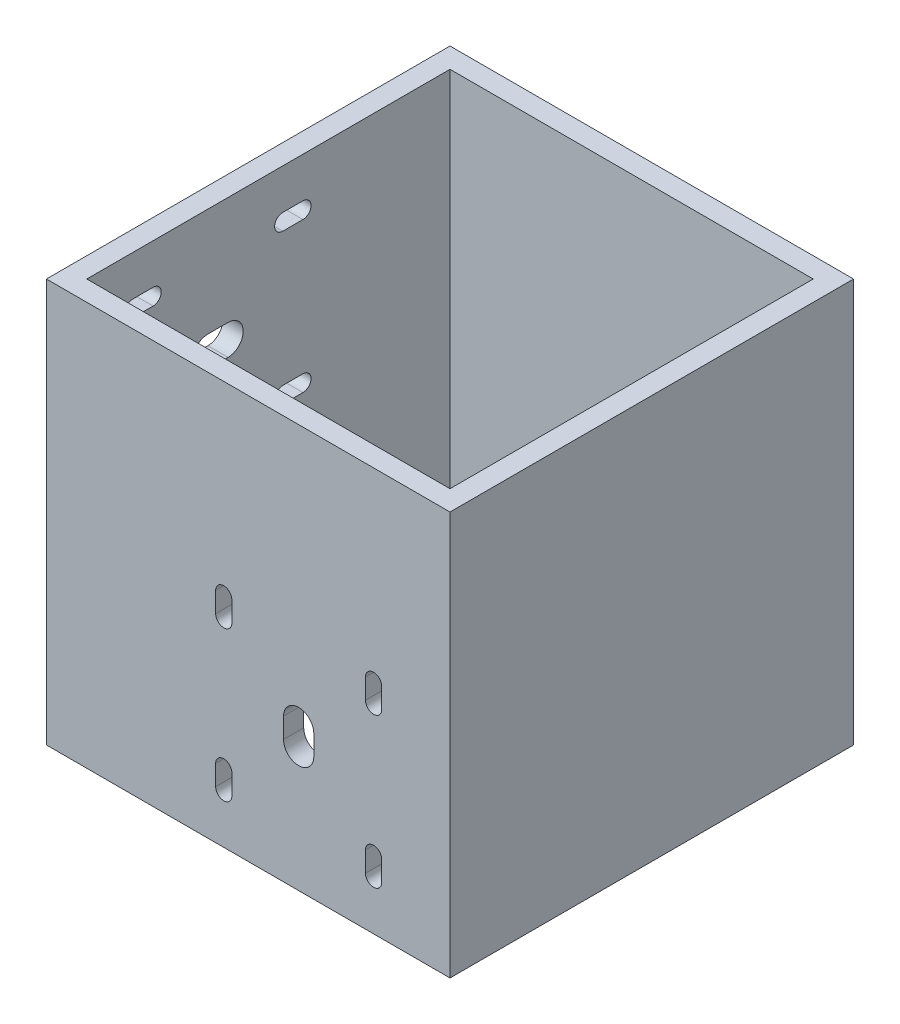
from build123d import *

# Parameters (mm, degrees)
SKETCH2_W           = 127
SKETCH2_H           = 127
SKETCH2_W_2         = 114.3
SKETCH2_H_2         = 114.3
BOSS_EXTRUDE2_DEPTH = 127
CUT_EXTRUDE1_REACH  = 129
CUT_EXTRUDE2_REACH  = 129


with BuildPart() as part:
    # Sketch2 → Boss-Extrude2 (new body)
    with BuildSketch(Plane(origin=(0, 0, 0), x_dir=(1, 0, 0), z_dir=(0, 1, 0))):
        Rectangle(SKETCH2_W, SKETCH2_H)
        Rectangle(SKETCH2_W_2, SKETCH2_H_2, mode=Mode.SUBTRACT)
    extrude(amount=BOSS_EXTRUDE2_DEPTH)

    # Sketch6 → Cut-Extrude1 (cut, up to next)
    with BuildSketch(Plane.ZY.offset(63.5), mode=Mode.PRIVATE) as cut_extrude1_sk1:
        with BuildLine():
            Line((-4.523172318, 109.1946), (-10.873172318, 109.1946))
            ThreePointArc((-10.873172318, 109.1946), (-13.425872318, 111.7473), (-10.873172318, 114.3))
            Line((-10.873172318, 114.3), (-4.523172318, 114.3))
            ThreePointArc((-4.523172318, 114.3), (-1.970472318, 111.7473), (-4.523172318, 109.1946))
        make_face()
    cut_extrude1_tool1 = extrude(cut_extrude1_sk1.sketch, amount=-CUT_EXTRUDE1_REACH, mode=Mode.PRIVATE) & part.part
    add(cut_extrude1_tool1.solids().sort_by_distance((-63.5, 111.7473, -7.698172))[0], mode=Mode.SUBTRACT)
    # Sketch6 → Cut-Extrude1 (cut, up to next)
    with BuildSketch(Plane.ZY.offset(63.5), mode=Mode.PRIVATE) as cut_extrude1_sk2:
        with BuildLine():
            Line((36.273172318, 114.3), (42.623172318, 114.3))
            ThreePointArc((42.623172318, 114.3), (45.175872318, 111.7473), (42.623172318, 109.1946))
            Line((42.623172318, 109.1946), (36.273172318, 109.1946))
            ThreePointArc((36.273172318, 109.1946), (33.720472318, 111.7473), (36.273172318, 114.3))
        make_face()
    cut_extrude1_tool2 = extrude(cut_extrude1_sk2.sketch, amount=-CUT_EXTRUDE1_REACH, mode=Mode.PRIVATE) & part.part
    add(cut_extrude1_tool2.solids().sort_by_distance((-63.5, 111.7473, 39.448172))[0], mode=Mode.SUBTRACT)
    # Sketch6 → Cut-Extrude1 (cut, up to next)
    with BuildSketch(Plane.ZY.offset(63.5), mode=Mode.PRIVATE) as cut_extrude1_sk3:
        with BuildLine():
            Line((36.273172318, 67.153655364), (42.623172318, 67.153655364))
            ThreePointArc((42.623172318, 67.153655364), (45.175872318, 64.600955364), (42.623172318, 62.048255364))
            Line((42.623172318, 62.048255364), (36.273172318, 62.048255364))
            ThreePointArc((36.273172318, 62.048255364), (33.720472318, 64.600955364), (36.273172318, 67.153655364))
        make_face()
    cut_extrude1_tool3 = extrude(cut_extrude1_sk3.sketch, amount=-CUT_EXTRUDE1_REACH, mode=Mode.PRIVATE) & part.part
    add(cut_extrude1_tool3.solids().sort_by_distance((-63.5, 64.600955, 39.448172))[0], mode=Mode.SUBTRACT)
    # Sketch6 → Cut-Extrude1 (cut, up to next)
    with BuildSketch(Plane.ZY.offset(63.5), mode=Mode.PRIVATE) as cut_extrude1_sk4:
        with BuildLine():
            Line((-4.523172318, 62.048255364), (-10.873172318, 62.048255364))
            ThreePointArc((-10.873172318, 62.048255364), (-13.425872318, 64.600955364), (-10.873172318, 67.153655364))
            Line((-10.873172318, 67.153655364), (-4.523172318, 67.153655364))
            ThreePointArc((-4.523172318, 67.153655364), (-1.970472318, 64.600955364), (-4.523172318, 62.048255364))
        make_face()
    cut_extrude1_tool4 = extrude(cut_extrude1_sk4.sketch, amount=-CUT_EXTRUDE1_REACH, mode=Mode.PRIVATE) & part.part
    add(cut_extrude1_tool4.solids().sort_by_distance((-63.5, 64.600955, -7.698172))[0], mode=Mode.SUBTRACT)
    # Sketch6 → Cut-Extrude1 (cut, up to next)
    with BuildSketch(Plane.ZY.offset(63.5), mode=Mode.PRIVATE) as cut_extrude1_sk5:
        with BuildLine():
            Line((19.05, 83.411627682), (12.7, 83.411627682))
            ThreePointArc((12.7, 83.411627682), (7.9375, 88.174127682), (12.7, 92.936627682))
            Line((12.7, 92.936627682), (19.05, 92.936627682))
            ThreePointArc((19.05, 92.936627682), (23.8125, 88.174127682), (19.05, 83.411627682))
        make_face()
    cut_extrude1_tool5 = extrude(cut_extrude1_sk5.sketch, amount=-CUT_EXTRUDE1_REACH, mode=Mode.PRIVATE) & part.part
    add(cut_extrude1_tool5.solids().sort_by_distance((-63.5, 88.174128, 15.875))[0], mode=Mode.SUBTRACT)

    # Sketch8 → Cut-Extrude2 (cut, up to next)
    with BuildSketch(Plane.XY.offset(63.5), mode=Mode.PRIVATE) as cut_extrude2_sk1:
        with BuildLine():
            Line((-10.250872318, 62.399044636), (-10.250872318, 68.749044636))
            ThreePointArc((-10.250872318, 68.749044636), (-7.698172318, 71.301744636), (-5.145472318, 68.749044636))
            Line((-5.145472318, 68.749044636), (-5.145472318, 62.399044636))
            ThreePointArc((-5.145472318, 62.399044636), (-7.698172318, 59.846344636), (-10.250872318, 62.399044636))
        make_face()
    cut_extrude2_tool1 = extrude(cut_extrude2_sk1.sketch, amount=-CUT_EXTRUDE2_REACH, mode=Mode.PRIVATE) & part.part
    add(cut_extrude2_tool1.solids().sort_by_distance((-7.698172, 65.574045, 63.5))[0], mode=Mode.SUBTRACT)
    # Sketch8 → Cut-Extrude2 (cut, up to next)
    with BuildSketch(Plane.XY.offset(63.5), mode=Mode.PRIVATE) as cut_extrude2_sk2:
        with BuildLine():
            Line((36.895472318, 62.399044636), (36.895472318, 68.749044636))
            ThreePointArc((36.895472318, 68.749044636), (39.448172318, 71.301744636), (42.000872318, 68.749044636))
            Line((42.000872318, 68.749044636), (42.000872318, 62.399044636))
            ThreePointArc((42.000872318, 62.399044636), (39.448172318, 59.846344636), (36.895472318, 62.399044636))
        make_face()
    cut_extrude2_tool2 = extrude(cut_extrude2_sk2.sketch, amount=-CUT_EXTRUDE2_REACH, mode=Mode.PRIVATE) & part.part
    add(cut_extrude2_tool2.solids().sort_by_distance((39.448172, 65.574045, 63.5))[0], mode=Mode.SUBTRACT)
    # Sketch8 → Cut-Extrude2 (cut, up to next)
    with BuildSketch(Plane.XY.offset(63.5), mode=Mode.PRIVATE) as cut_extrude2_sk3:
        with BuildLine():
            Line((42.000872318, 21.6027), (42.000872318, 15.2527))
            ThreePointArc((42.000872318, 15.2527), (39.448172318, 12.7), (36.895472318, 15.2527))
            Line((36.895472318, 15.2527), (36.895472318, 21.6027))
            ThreePointArc((36.895472318, 21.6027), (39.448172318, 24.1554), (42.000872318, 21.6027))
        make_face()
    cut_extrude2_tool3 = extrude(cut_extrude2_sk3.sketch, amount=-CUT_EXTRUDE2_REACH, mode=Mode.PRIVATE) & part.part
    add(cut_extrude2_tool3.solids().sort_by_distance((39.448172, 18.4277, 63.5))[0], mode=Mode.SUBTRACT)
    # Sketch8 → Cut-Extrude2 (cut, up to next)
    with BuildSketch(Plane.XY.offset(63.5), mode=Mode.PRIVATE) as cut_extrude2_sk4:
        with BuildLine():
            Line((-10.250872318, 15.2527), (-10.250872318, 21.6027))
            ThreePointArc((-10.250872318, 21.6027), (-7.698172318, 24.1554), (-5.145472318, 21.6027))
            Line((-5.145472318, 21.6027), (-5.145472318, 15.2527))
            ThreePointArc((-5.145472318, 15.2527), (-7.698172318, 12.7), (-10.250872318, 15.2527))
        make_face()
    cut_extrude2_tool4 = extrude(cut_extrude2_sk4.sketch, amount=-CUT_EXTRUDE2_REACH, mode=Mode.PRIVATE) & part.part
    add(cut_extrude2_tool4.solids().sort_by_distance((-7.698172, 18.4277, 63.5))[0], mode=Mode.SUBTRACT)
    # Sketch8 → Cut-Extrude2 (cut, up to next)
    with BuildSketch(Plane.XY.offset(63.5), mode=Mode.PRIVATE) as cut_extrude2_sk5:
        with BuildLine():
            Line((11.1125, 38.825872318), (11.1125, 45.175872318))
            ThreePointArc((11.1125, 45.175872318), (15.875, 49.938372318), (20.6375, 45.175872318))
            Line((20.6375, 45.175872318), (20.6375, 38.825872318))
            ThreePointArc((20.6375, 38.825872318), (15.875, 34.063372318), (11.1125, 38.825872318))
        make_face()
    cut_extrude2_tool5 = extrude(cut_extrude2_sk5.sketch, amount=-CUT_EXTRUDE2_REACH, mode=Mode.PRIVATE) & part.part
    add(cut_extrude2_tool5.solids().sort_by_distance((15.875, 42.000872, 63.5))[0], mode=Mode.SUBTRACT)


solid = part.part
